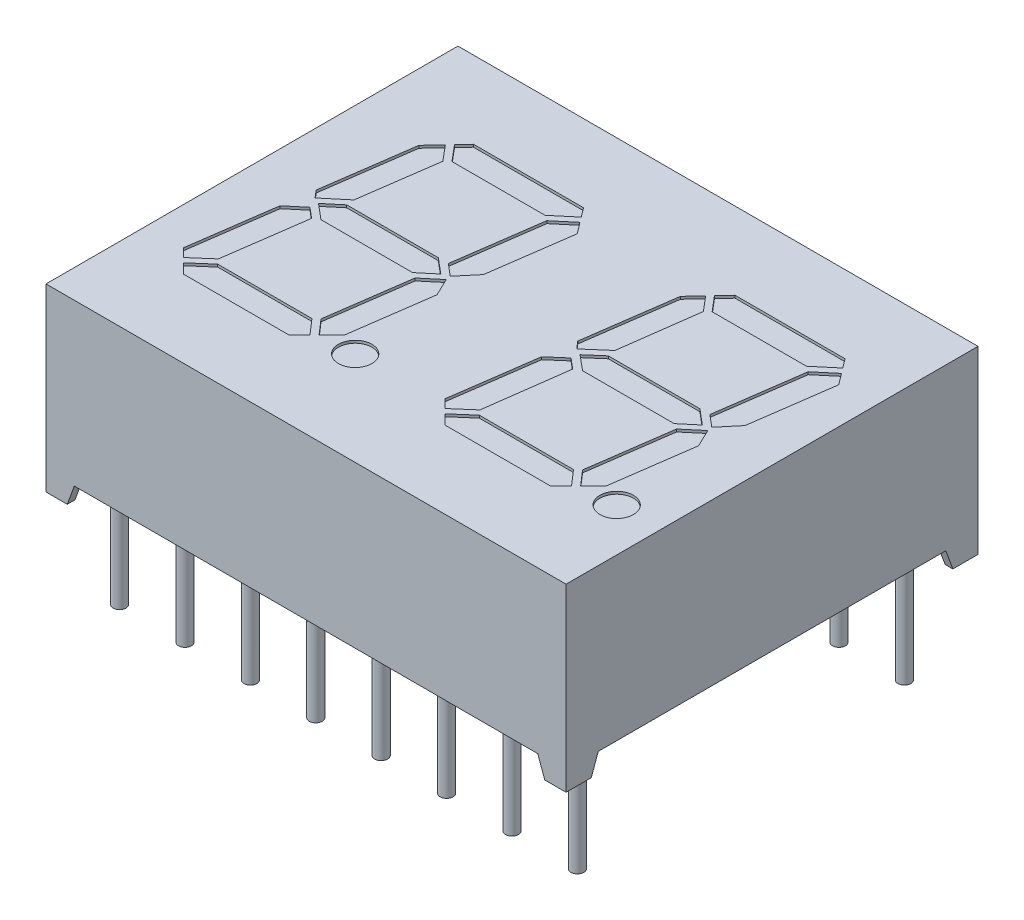
from build123d import *

# Parameters (mm, degrees)
SKETCH1_W          = 20.2
SKETCH1_H          = 16
EXTRUDE2_DEPTH     = 7
CUT_EXTRUDE2_DEPTH = 17
CUT_EXTRUDE3_DEPTH = 21.2
SKETCH6_R          = 0.65
CUT_EXTRUDE4_DEPTH = 0.1
SKETCH7_W          = 0.8
SKETCH7_H          = 0.95
CUT_EXTRUDE6_DEPTH = 0.75
SKETCH7_3_R        = 0.25
EXTRUDE3_DEPTH     = 0.75
SKETCH7_4_R        = 0.25
EXTRUDE4_DEPTH     = 4
SKETCH8_W          = 0.026582278
SKETCH8_H          = 0.025316456
CUT_EXTRUDE7_DEPTH = 0.01


with BuildPart() as part:
    # Sketch1 → Extrude2 (new body)
    with BuildSketch(Plane(origin=(0, 0, 0), x_dir=(1, 0, 0), z_dir=(0, 1, 0))):
        Rectangle(SKETCH1_W, SKETCH1_H)
    extrude(amount=-EXTRUDE2_DEPTH)

    # Sketch2 → Cut-Extrude2 (cut, through all)
    with BuildSketch(Plane.XY.offset(8)):
        Polygon((-9.272977676, -7), (-9, -6.25), (9, -6.25), (9.272977676, -7), align=None)
    extrude(amount=-CUT_EXTRUDE2_DEPTH, mode=Mode.SUBTRACT)

    # Sketch3 → Cut-Extrude3 (cut, through all)
    with BuildSketch(Plane(origin=(10.1, 0, 0), x_dir=(0, 0, -1), z_dir=(1, 0, 0))):
        Polygon((-7.022977676, -7), (-6.75, -6.25), (6.75, -6.25), (7.022977676, -7), align=None)
    extrude(amount=-CUT_EXTRUDE3_DEPTH, mode=Mode.SUBTRACT)

    # Sketch6 → Cut-Extrude4 (cut)
    with BuildSketch(Plane(origin=(0, 0, 0), x_dir=(-1, 0, 0), z_dir=(0, 1, 0))):
        Polygon((7.023157222, -4.434522221), (7.518838203, -3.902969448), (8.010346899, -0.405703354), (7.766925496, -0.115605022), (6.944276877, -0.805889175), (6.51878336, -3.833432859), align=None)
        Polygon((7.552018427, 0.295933465), (8.183414669, 0.825737819), (8.645847239, 4.116116524), (8.319373753, 4.442590009), (7.593183674, 3.811322605), (7.146902379, 0.635866191), align=None)
        Polygon((6.495840663, -5), (6.85137721, -4.618733731), (6.332197964, -4), (2.716150111, -4), (1.952076151, -4.641134178), (2.222500945, -5), align=None)
        Polygon((6.919890443, -0.5), (7.51576724, 0), (6.919890443, 0.5), (3.361644036, 0.5), (2.76576724, 0), (3.361644036, -0.5), align=None)
        Polygon((7.429168917, 4), (8.142165387, 4.619798375), (7.761963762, 5), (3.646933493, 5), (3.247868188, 4.600934695), (3.770252749, 4), align=None)
        Polygon((1.801415921, -4.441201299), (2.500765363, -3.85437744), (2.972247297, -0.499609162), (2.506523905, -0.108820836), (1.91892437, -0.809094694), (1.470232166, -4.001705612), align=None)
        Polygon((3.131453053, 0.633198654), (3.581575354, 3.835985243), (3.070659822, 4.423726329), (2.586273321, 3.939339828), (2.141084503, 0.771656793), (2.473271796, 0.080919003), align=None)
        Polygon((-3.662169854, -4.999993227), (-3.276767134, -4.586267598), (-3.774624408, -3.999993227), (-7.437307761, -3.999993227), (-8.204404285, -4.643663637), (-7.935509571, -4.999993227), align=None)
        Polygon((-3.595238623, -3.839578876), (-3.111665282, -4.409032555), (-2.64024003, -3.902962674), (-2.148731334, -0.40569658), (-2.395060048, -0.121837585), (-3.187587279, -0.809581206), align=None)
        Polygon((-8.688846066, -4.001698839), (-8.35955355, -4.43806542), (-7.656370358, -3.848024664), (-7.186090035, -0.499128511), (-7.652014866, -0.108171158), (-8.240153863, -0.80908792), align=None)
        Polygon((-2.58634694, 0.295802426), (-1.975663564, 0.825744592), (-1.513230994, 4.116123297), (-1.839521605, 4.442413908), (-2.565949288, 3.810939957), (-2.993458449, 0.633342778), align=None)
        Polygon((-2.651691466, 0.009827552), (-3.242886226, 0.499993227), (-6.79742283, 0.499993227), (-7.393310993, 6.773e-06), (-6.797434197, -0.499993227), (-3.239187789, -0.499993227), align=None)
        Polygon((-7.572804912, 3.939346602), (-8.017993729, 0.771663567), (-7.685806437, 0.080925777), (-7.027009117, 0.633696842), (-6.577239772, 3.836533016), (-7.08807549, 4.424076024), align=None)
        Polygon((-2.730302564, 4.000006773), (-2.01709572, 4.619988024), (-2.39711447, 5.000006773), (-6.51214474, 5.000006773), (-6.911470939, 4.600680574), (-6.389218732, 4.000006773), align=None)
        with Locations(Location((1.74076724, 4.35, 0), (0, 0, 270))):  # turned: the seam where the file's is
            Circle(SKETCH6_R)
        with Locations(Location((-8.417243277, 4.350397611, 0), (0, 0, 270))):  # turned: the seam where the file's is
            Circle(SKETCH6_R)
    extrude(amount=-CUT_EXTRUDE4_DEPTH, mode=Mode.SUBTRACT)

    # Sketch7 → Cut-Extrude6 (cut)
    with BuildSketch(Plane.XZ.offset(7)):
        with Locations((-9.4, 7.225)):
            Rectangle(SKETCH7_W, SKETCH7_H)
        with Locations((-9.4, -7.225)):
            Rectangle(SKETCH7_W, SKETCH7_H)
        with Locations((9.4, -7.225)):
            Rectangle(SKETCH7_W, SKETCH7_H)
        with Locations((9.4, 7.225)):
            Rectangle(SKETCH7_W, SKETCH7_H)
    extrude(amount=-CUT_EXTRUDE6_DEPTH, mode=Mode.SUBTRACT)

    # Sketch7_3 → Extrude3 (add)
    with BuildSketch(Plane.XZ.offset(7)):
        with Locations(Location((-3.81, 6.35, 0), (0, 0, 270))):  # turned: the seam where the file's is
            Circle(SKETCH7_3_R)
        with Locations(Location((-1.27, 6.35, 0), (0, 0, 270))):  # turned: the seam where the file's is
            Circle(SKETCH7_3_R)
        with Locations(Location((1.27, 6.35, 0), (0, 0, 270))):  # turned: the seam where the file's is
            Circle(SKETCH7_3_R)
        with Locations(Location((3.81, 6.35, 0), (0, 0, 270))):  # turned: the seam where the file's is
            Circle(SKETCH7_3_R)
        with Locations(Location((6.35, 6.35, 0), (0, 0, 270))):  # turned: the seam where the file's is
            Circle(SKETCH7_3_R)
        with Locations(Location((6.35, -6.35, 0), (0, 0, 270))):  # turned: the seam where the file's is
            Circle(SKETCH7_3_R)
        with Locations(Location((3.81, -6.35, 0), (0, 0, 270))):  # turned: the seam where the file's is
            Circle(SKETCH7_3_R)
        with Locations(Location((1.27, -6.35, 0), (0, 0, 270))):  # turned: the seam where the file's is
            Circle(SKETCH7_3_R)
        with Locations(Location((-1.27, -6.35, 0), (0, 0, 270))):  # turned: the seam where the file's is
            Circle(SKETCH7_3_R)
        with Locations(Location((-3.81, -6.35, 0), (0, 0, 270))):  # turned: the seam where the file's is
            Circle(SKETCH7_3_R)
        with Locations(Location((-6.35, 6.35, 0), (0, 0, 270))):  # turned: the seam where the file's is
            Circle(SKETCH7_3_R)
        with Locations(Location((-8.89, 6.35, 0), (0, 0, 270))):  # turned: the seam where the file's is
            Circle(SKETCH7_3_R)
        with Locations(Location((8.89, 6.35, 0), (0, 0, 270))):  # turned: the seam where the file's is
            Circle(SKETCH7_3_R)
        with Locations(Location((-8.89, -6.35, 0), (0, 0, 270))):  # turned: the seam where the file's is
            Circle(SKETCH7_3_R)
        with Locations(Location((-6.35, -6.35, 0), (0, 0, 270))):  # turned: the seam where the file's is
            Circle(SKETCH7_3_R)
        with Locations(Location((8.89, -6.35, 0), (0, 0, 270))):  # turned: the seam where the file's is
            Circle(SKETCH7_3_R)
    extrude(amount=-EXTRUDE3_DEPTH)

    # Sketch7_4 → Extrude4 (add)
    with BuildSketch(Plane.XZ.offset(7)):
        with Locations(Location((-3.81, 6.35, 0), (0, 0, 270))):  # turned: the seam where the file's is
            Circle(SKETCH7_4_R)
        with Locations(Location((-1.27, 6.35, 0), (0, 0, 270))):  # turned: the seam where the file's is
            Circle(SKETCH7_4_R)
        with Locations(Location((1.27, 6.35, 0), (0, 0, 270))):  # turned: the seam where the file's is
            Circle(SKETCH7_4_R)
        with Locations(Location((3.81, 6.35, 0), (0, 0, 270))):  # turned: the seam where the file's is
            Circle(SKETCH7_4_R)
        with Locations(Location((6.35, 6.35, 0), (0, 0, 270))):  # turned: the seam where the file's is
            Circle(SKETCH7_4_R)
        with Locations(Location((6.35, -6.35, 0), (0, 0, 270))):  # turned: the seam where the file's is
            Circle(SKETCH7_4_R)
        with Locations(Location((3.81, -6.35, 0), (0, 0, 270))):  # turned: the seam where the file's is
            Circle(SKETCH7_4_R)
        with Locations(Location((1.27, -6.35, 0), (0, 0, 270))):  # turned: the seam where the file's is
            Circle(SKETCH7_4_R)
        with Locations(Location((-1.27, -6.35, 0), (0, 0, 270))):  # turned: the seam where the file's is
            Circle(SKETCH7_4_R)
        with Locations(Location((-3.81, -6.35, 0), (0, 0, 270))):  # turned: the seam where the file's is
            Circle(SKETCH7_4_R)
        with Locations(Location((-6.35, 6.35, 0), (0, 0, 270))):  # turned: the seam where the file's is
            Circle(SKETCH7_4_R)
        with Locations(Location((-8.89, 6.35, 0), (0, 0, 270))):  # turned: the seam where the file's is
            Circle(SKETCH7_4_R)
        with Locations(Location((8.89, 6.35, 0), (0, 0, 270))):  # turned: the seam where the file's is
            Circle(SKETCH7_4_R)
        with Locations(Location((-8.89, -6.35, 0), (0, 0, 270))):  # turned: the seam where the file's is
            Circle(SKETCH7_4_R)
        with Locations(Location((-6.35, -6.35, 0), (0, 0, 270))):  # turned: the seam where the file's is
            Circle(SKETCH7_4_R)
        with Locations(Location((8.89, -6.35, 0), (0, 0, 270))):  # turned: the seam where the file's is
            Circle(SKETCH7_4_R)
    extrude(amount=EXTRUDE4_DEPTH)

    # Sketch8 → Cut-Extrude7 (cut)
    with BuildSketch(Plane.XZ.offset(6.25)):
        Polygon((-8.815316456, 0.572151899), (-8.89, 0.595609177), (-8.89, 0.620352057), (-8.839663766, 0.636768196), (-8.89, 0.652294304), (-8.89, 0.678026108), (-8.815316456, 0.701265823), (-8.815316456, 0.676087816), (-8.866799842, 0.663093354), (-8.815316456, 0.646677215), (-8.815316456, 0.625178006), (-8.866799842, 0.608860759), (-8.815316456, 0.596044304), align=None)
        Polygon((-8.815316456, 0.437974684), (-8.89, 0.461431962), (-8.89, 0.486174842), (-8.839663766, 0.502590981), (-8.89, 0.518117089), (-8.89, 0.543848892), (-8.815316456, 0.567088608), (-8.815316456, 0.541910601), (-8.866799842, 0.528916139), (-8.815316456, 0.5125), (-8.815316456, 0.491000791), (-8.866799842, 0.474683544), (-8.815316456, 0.461867089), align=None)
        Polygon((-8.815316456, 0.303797468), (-8.89, 0.327254747), (-8.89, 0.351997627), (-8.839663766, 0.368413766), (-8.89, 0.383939873), (-8.89, 0.409671677), (-8.815316456, 0.432911392), (-8.815316456, 0.407733386), (-8.866799842, 0.394738924), (-8.815316456, 0.378322785), (-8.815316456, 0.356823576), (-8.866799842, 0.340506329), (-8.815316456, 0.327689873), align=None)
        with Locations((-8.876708861, 0.275949367)):
            Rectangle(SKETCH8_W, SKETCH8_H)
        with BuildLine():
            add(Edge.make_bspline(
                [(-8.858829114, 0.159493671), (-8.860051248, 0.159530169), (-8.86245111, 0.15960184), (-8.865958798, 0.160211426), (-8.869283102, 0.161205393), (-8.872447248, 0.162577732), (-8.875416736, 0.164371189), (-8.878219628, 0.16655446), (-8.880824172, 0.169143343), (-8.883260547, 0.172090146), (-8.885442658, 0.175387089), (-8.887348691, 0.178984804), (-8.888943362, 0.18286483), (-8.890282428, 0.187013042), (-8.891270861, 0.191459588), (-8.891994849, 0.196177087), (-8.892468166, 0.201170514), (-8.892510134, 0.204594091), (-8.892531646, 0.206348892)],
                knots=[0, 0, 0, 0, 0.907312236, 1.78165839, 2.635367075, 3.479697475, 4.336364812, 5.205276731, 6.11257575, 7.058770404, 8.040786331, 9.044147278, 10.078219212, 11.153049307, 12.278104542, 13.457648573, 14.696882856, 16, 16, 16, 16], degree=3))
            add(Edge.make_bspline(
                [(-8.892531646, 0.206348892), (-8.892507574, 0.208367148), (-8.892460949, 0.21227633), (-8.89203235, 0.217939855), (-8.891386211, 0.223207892), (-8.890419669, 0.228103607), (-8.889218904, 0.232708206), (-8.887927612, 0.237141474), (-8.886463197, 0.241422786), (-8.885363039, 0.244195876), (-8.884818038, 0.24556962)],
                knots=[0, 0, 0, 0, 1.203215828, 2.33052265, 3.384689099, 4.366106119, 5.303329643, 6.221311756, 7.118865988, 8, 8, 8, 8], degree=3))
            Line((-8.884818038, 0.24556962), (-8.860886076, 0.24556962))
            Line((-8.860886076, 0.24556962), (-8.860886076, 0.242721519))
            add(Edge.make_bspline(
                [(-8.860886076, 0.242721519), (-8.861967531, 0.241356205), (-8.864124092, 0.238633592), (-8.866886697, 0.234200359), (-8.86928886, 0.229552713), (-8.871262862, 0.224707243), (-8.872849186, 0.219810398), (-8.873942713, 0.21493502), (-8.874690062, 0.210169433), (-8.874770569, 0.207010864), (-8.874810127, 0.205458861)],
                knots=[0, 0, 0, 0, 1.030622468, 2.055194264, 3.087043286, 4.125157485, 5.149848264, 6.130935704, 7.081611712, 8, 8, 8, 8], degree=3))
            add(Edge.make_bspline(
                [(-8.874810127, 0.205458861), (-8.874809232, 0.205030082), (-8.874807317, 0.2041121), (-8.874678474, 0.202644063), (-8.874585311, 0.200985464), (-8.874376093, 0.199206598), (-8.87415751, 0.197415781), (-8.87377719, 0.195761121), (-8.873415351, 0.194257482), (-8.873047173, 0.193351), (-8.872871835, 0.192919304)],
                knots=[0, 0, 0, 0, 0.806378557, 1.726393851, 2.771014456, 3.931269413, 5.096090628, 6.161710732, 7.124547685, 8, 8, 8, 8], degree=3))
            add(Edge.make_bspline(
                [(-8.872871835, 0.192919304), (-8.872644012, 0.192439517), (-8.87219629, 0.191496634), (-8.871378683, 0.190201714), (-8.870507381, 0.189019042), (-8.869541962, 0.187957582), (-8.868364053, 0.187107314), (-8.866963197, 0.186479113), (-8.865312897, 0.186136019), (-8.864137886, 0.186096725), (-8.863516614, 0.186075949)],
                knots=[0, 0, 0, 0, 1.024407818, 2.013179384, 2.949802342, 3.859052226, 4.77034807, 5.732977883, 6.801339628, 8, 8, 8, 8], degree=3))
            add(Edge.make_bspline(
                [(-8.863516614, 0.186075949), (-8.862970718, 0.186107391), (-8.861897325, 0.186169215), (-8.860369329, 0.186751006), (-8.858947452, 0.187633905), (-8.857686737, 0.188920927), (-8.856529299, 0.190515003), (-8.855559002, 0.19247074), (-8.854678928, 0.194723719), (-8.854261659, 0.196368178), (-8.854042722, 0.197231013)],
                knots=[0, 0, 0, 0, 0.825212765, 1.622611382, 2.449701629, 3.348069183, 4.336544339, 5.428209675, 6.6506027, 8, 8, 8, 8], degree=3))
            add(Edge.make_bspline(
                [(-8.854042722, 0.197231013), (-8.853594981, 0.19919974), (-8.852677791, 0.203232648), (-8.851530684, 0.209380757), (-8.850264611, 0.215510984), (-8.84905507, 0.219469696), (-8.84846519, 0.221400316)],
                knots=[0, 0, 0, 0, 0.976104583, 1.999535498, 3.024395274, 4, 4, 4, 4], degree=3))
            add(Edge.make_bspline(
                [(-8.84846519, 0.221400316), (-8.848112197, 0.222438832), (-8.847425064, 0.224460401), (-8.846263439, 0.227351945), (-8.844993487, 0.230013057), (-8.843638356, 0.232453168), (-8.842164358, 0.23465249), (-8.840630968, 0.236647679), (-8.838977131, 0.238391205), (-8.837245211, 0.239938889), (-8.835393209, 0.241262203), (-8.833449072, 0.242416954), (-8.831388607, 0.243392589), (-8.829227318, 0.244201473), (-8.82694845, 0.244818545), (-8.824571576, 0.245239801), (-8.822088216, 0.24553819), (-8.820393863, 0.245559001), (-8.819529272, 0.24556962)],
                knots=[0, 0, 0, 0, 1.287286806, 2.505824366, 3.654938963, 4.74627059, 5.778586806, 6.75996495, 7.696030012, 8.595059759, 9.482019644, 10.363222407, 11.245851011, 12.154256429, 13.068444161, 14.012503255, 14.985824751, 16, 16, 16, 16], degree=3))
            add(Edge.make_bspline(
                [(-8.819529272, 0.24556962), (-8.818373127, 0.245532318), (-8.816097855, 0.245458909), (-8.812768811, 0.24485748), (-8.809620074, 0.24383089), (-8.806616611, 0.242444827), (-8.803803525, 0.240616199), (-8.801124978, 0.238431404), (-8.798653386, 0.235807357), (-8.796353053, 0.232830235), (-8.794273654, 0.229542851), (-8.792443098, 0.226003867), (-8.790906446, 0.222234578), (-8.789632552, 0.218249032), (-8.788677881, 0.214030563), (-8.78795895, 0.20959333), (-8.787545768, 0.204919541), (-8.787494518, 0.20172812), (-8.787468354, 0.200098892)],
                knots=[0, 0, 0, 0, 0.894990994, 1.761326291, 2.609044902, 3.454222546, 4.315366365, 5.200560057, 6.125081389, 7.100429509, 8.110379559, 9.133447974, 10.182136699, 11.259192205, 12.370181258, 13.528580438, 14.738335141, 16, 16, 16, 16], degree=3))
            add(Edge.make_bspline(
                [(-8.787468354, 0.200098892), (-8.787490546, 0.198430205), (-8.787534891, 0.19509566), (-8.787912869, 0.190114218), (-8.788468097, 0.185153716), (-8.789309803, 0.180289886), (-8.79028622, 0.175599331), (-8.791382015, 0.171186095), (-8.79261998, 0.167106634), (-8.793574325, 0.16453297), (-8.79403481, 0.163291139)],
                knots=[0, 0, 0, 0, 1.065403572, 2.129000689, 3.188532477, 4.251604565, 5.279552602, 6.247508681, 7.154397237, 8, 8, 8, 8], degree=3))
            Line((-8.79403481, 0.163291139), (-8.816582278, 0.163291139))
            Line((-8.816582278, 0.163291139), (-8.816582278, 0.166119462))
            add(Edge.make_bspline(
                [(-8.816582278, 0.166119462), (-8.815781932, 0.167192367), (-8.814145202, 0.169386485), (-8.81206153, 0.173046122), (-8.810103664, 0.177004358), (-8.808419505, 0.181283188), (-8.806960024, 0.185742216), (-8.805940858, 0.190325174), (-8.805299048, 0.194951338), (-8.805226273, 0.198053049), (-8.805189873, 0.19960443)],
                knots=[0, 0, 0, 0, 0.892283326, 1.824742884, 2.804416662, 3.836872171, 4.8899239, 5.931447339, 6.965372909, 8, 8, 8, 8], degree=3))
            add(Edge.make_bspline(
                [(-8.805189873, 0.19960443), (-8.805211326, 0.200700098), (-8.805254228, 0.202891315), (-8.805644912, 0.206159523), (-8.806275806, 0.209401584), (-8.807095088, 0.211442107), (-8.807503956, 0.212460443)],
                knots=[0, 0, 0, 0, 0.999146175, 1.998183711, 3.000980573, 4, 4, 4, 4], degree=3))
            add(Edge.make_bspline(
                [(-8.807503956, 0.212460443), (-8.807705423, 0.212893946), (-8.808108222, 0.213760664), (-8.808880786, 0.214967308), (-8.809809597, 0.216071977), (-8.810861589, 0.217064055), (-8.812017962, 0.217932452), (-8.813292788, 0.218547803), (-8.814655703, 0.218923676), (-8.815590934, 0.218965835), (-8.816068038, 0.218987342)],
                knots=[0, 0, 0, 0, 1.00524851, 2.009826503, 3.004679593, 4.035271301, 5.048246368, 6.034938417, 6.997532266, 8, 8, 8, 8], degree=3))
            add(Edge.make_bspline(
                [(-8.816068038, 0.218987342), (-8.816706203, 0.218952904), (-8.817925679, 0.218887095), (-8.819641475, 0.218280511), (-8.821119909, 0.217295678), (-8.822114829, 0.216135073), (-8.822812267, 0.215017943), (-8.823322777, 0.213982284), (-8.823806136, 0.212773057), (-8.824303605, 0.211401809), (-8.824794792, 0.209865482), (-8.825270339, 0.208156925), (-8.825719635, 0.206274208), (-8.826005825, 0.204958333), (-8.826155063, 0.204272152)],
                knots=[0, 0, 0, 0, 1.173816843, 2.243057204, 3.312297565, 4.415174738, 5.03266065, 5.73970059, 6.541434878, 7.433956553, 8.430083051, 9.515931566, 10.70464786, 12, 12, 12, 12], degree=3))
            add(Edge.make_bspline(
                [(-8.826155063, 0.204272152), (-8.826531125, 0.202439363), (-8.827270003, 0.198838337), (-8.828373491, 0.193437153), (-8.82964846, 0.18793438), (-8.830797263, 0.184269053), (-8.831396361, 0.182357595)],
                knots=[0, 0, 0, 0, 0.995744513, 1.956417928, 2.934277412, 4, 4, 4, 4], degree=3))
            add(Edge.make_bspline(
                [(-8.831396361, 0.182357595), (-8.831715605, 0.181411041), (-8.832340097, 0.179559428), (-8.83342638, 0.176918797), (-8.834600363, 0.174471738), (-8.835841894, 0.172204706), (-8.83718586, 0.170130736), (-8.838608507, 0.168236053), (-8.840135416, 0.166552235), (-8.841748644, 0.16505467), (-8.843458744, 0.16373551), (-8.845297817, 0.162603212), (-8.847246619, 0.161630984), (-8.849332819, 0.160861379), (-8.851527406, 0.160243358), (-8.853858774, 0.159820261), (-8.85630315, 0.159526278), (-8.857977728, 0.159504661), (-8.858829114, 0.159493671)],
                knots=[0, 0, 0, 0, 1.237467875, 2.420686895, 3.535046182, 4.599015201, 5.620884487, 6.594603852, 7.531477383, 8.433220087, 9.318759595, 10.202828513, 11.105163009, 12.01247538, 12.953896178, 13.926381251, 14.945733412, 16, 16, 16, 16], degree=3))
        make_face()
        with BuildLine():
            Line((-8.89, 0.067088608), (-8.89, 0.091139241))
            Line((-8.89, 0.091139241), (-8.882167722, 0.091139241))
            add(Edge.make_bspline(
                [(-8.882167722, 0.091139241), (-8.88297628, 0.092232549), (-8.884535168, 0.094340433), (-8.886615386, 0.097513458), (-8.888390652, 0.100539548), (-8.889949873, 0.103453039), (-8.891125258, 0.106475242), (-8.891953324, 0.109706756), (-8.892453097, 0.113209581), (-8.892504881, 0.115636475), (-8.892531646, 0.116890823)],
                knots=[0, 0, 0, 0, 1.150872466, 2.218865267, 3.209461834, 4.120482262, 5.012764827, 5.946708227, 6.938749913, 8, 8, 8, 8], degree=3))
            add(Edge.make_bspline(
                [(-8.892531646, 0.116890823), (-8.892508927, 0.117907175), (-8.892464686, 0.119886305), (-8.892119808, 0.122763545), (-8.891582157, 0.125471173), (-8.890774566, 0.127986213), (-8.889808763, 0.130350202), (-8.888528805, 0.132487752), (-8.887098631, 0.134491354), (-8.885391585, 0.136273026), (-8.883493852, 0.137888648), (-8.881361392, 0.139271198), (-8.879028466, 0.140448909), (-8.876476612, 0.141390006), (-8.873718309, 0.142145096), (-8.870739061, 0.142669028), (-8.867551934, 0.142989621), (-8.865356803, 0.14302156), (-8.864228639, 0.143037975)],
                knots=[0, 0, 0, 0, 1.109008058, 2.159558935, 3.158726032, 4.116861086, 5.039058877, 5.938775559, 6.82970133, 7.720510853, 8.624361809, 9.544451588, 10.487360536, 11.471068125, 12.508000841, 13.604731202, 14.768976642, 16, 16, 16, 16], degree=3))
            Line((-8.864228639, 0.143037975), (-8.815316456, 0.143037975))
            Line((-8.815316456, 0.143037975), (-8.815316456, 0.118987342))
            Line((-8.815316456, 0.118987342), (-8.85289557, 0.118987342))
            add(Edge.make_bspline(
                [(-8.85289557, 0.118987342), (-8.853812041, 0.118985706), (-8.855566256, 0.118982576), (-8.858072063, 0.118900237), (-8.860340235, 0.118779336), (-8.862382264, 0.118640631), (-8.864229015, 0.118387615), (-8.865895176, 0.118009906), (-8.867414778, 0.11753908), (-8.868321479, 0.117074761), (-8.868757911, 0.116851266)],
                knots=[0, 0, 0, 0, 1.361401701, 2.605856924, 3.723918663, 4.735739235, 5.645738665, 6.489217889, 7.27279937, 8, 8, 8, 8], degree=3))
            add(Edge.make_bspline(
                [(-8.868757911, 0.116851266), (-8.869156626, 0.116621259), (-8.869940466, 0.116169086), (-8.870946644, 0.115248796), (-8.871790911, 0.114170053), (-8.87244694, 0.112892449), (-8.872945889, 0.111405901), (-8.873286125, 0.109677971), (-8.873501627, 0.107692609), (-8.873529535, 0.106283591), (-8.873544304, 0.105537975)],
                knots=[0, 0, 0, 0, 0.849138082, 1.669332372, 2.503455908, 3.370611167, 4.311442699, 5.394692208, 6.621337967, 8, 8, 8, 8], degree=3))
            add(Edge.make_bspline(
                [(-8.873544304, 0.105537975), (-8.873526947, 0.104996691), (-8.873491259, 0.103883773), (-8.873258814, 0.102172461), (-8.872902139, 0.100375884), (-8.872242283, 0.097861301), (-8.871056104, 0.094694674), (-8.869701697, 0.092335372), (-8.869015032, 0.091139241)],
                knots=[0, 0, 0, 0, 0.638127216, 1.312033637, 2.033062677, 2.79661882, 4.375931797, 6, 6, 6, 6], degree=3))
            Line((-8.869015032, 0.091139241), (-8.815316456, 0.091139241))
            Line((-8.815316456, 0.091139241), (-8.815316456, 0.067088608))
            Line((-8.815316456, 0.067088608), (-8.89, 0.067088608))
        make_face()
        with BuildLine():
            Line((-8.89, -0.030379747), (-8.89, -0.006329114))
            Line((-8.89, -0.006329114), (-8.852420886, -0.006329114))
            add(Edge.make_bspline(
                [(-8.852420886, -0.006329114), (-8.850890843, -0.0063046), (-8.847839818, -0.006255716), (-8.844077407, -0.005973592), (-8.841235083, -0.00559507), (-8.839397202, -0.005225415), (-8.837849063, -0.004793715), (-8.836963303, -0.004381435), (-8.836558544, -0.004193038)],
                knots=[0, 0, 0, 0, 1.709124929, 3.408128882, 4.211124727, 4.91016634, 5.501986363, 6, 6, 6, 6], degree=3))
            add(Edge.make_bspline(
                [(-8.836558544, -0.004193038), (-8.836160491, -0.003948575), (-8.835380051, -0.003469272), (-8.834367038, -0.002531948), (-8.833538197, -0.001438061), (-8.832856647, -0.000167292), (-8.832386066, 0.001323905), (-8.831992836, 0.003040645), (-8.831825927, 0.005027263), (-8.831790767, 0.006434533), (-8.831772152, 0.007179589)],
                knots=[0, 0, 0, 0, 0.86006424, 1.686277094, 2.52783008, 3.38194165, 4.331801563, 5.402842185, 6.624978739, 8, 8, 8, 8], degree=3))
            add(Edge.make_bspline(
                [(-8.831772152, 0.007179589), (-8.831828889, 0.00831141), (-8.831944743, 0.010622505), (-8.83265625, 0.013484698), (-8.833475209, 0.015815302), (-8.83423404, 0.017667827), (-8.835205482, 0.019576457), (-8.835927304, 0.020855869), (-8.836301424, 0.021518987)],
                knots=[0, 0, 0, 0, 1.338371478, 2.732853438, 3.468019217, 4.261884641, 5.099136535, 6, 6, 6, 6], degree=3))
            Line((-8.836301424, 0.021518987), (-8.89, 0.021518987))
            Line((-8.89, 0.021518987), (-8.89, 0.04556962))
            Line((-8.89, 0.04556962), (-8.815316456, 0.04556962))
            Line((-8.815316456, 0.04556962), (-8.815316456, 0.021518987))
            Line((-8.815316456, 0.021518987), (-8.823148734, 0.021518987))
            add(Edge.make_bspline(
                [(-8.823148734, 0.021518987), (-8.822342583, 0.020461581), (-8.82077336, 0.018403276), (-8.81873294, 0.015224038), (-8.816934171, 0.01214014), (-8.815421354, 0.009087131), (-8.814214579, 0.005972176), (-8.81340359, 0.002709417), (-8.812859787, -0.000706989), (-8.812810094, -0.003043704), (-8.81278481, -0.004232595)],
                knots=[0, 0, 0, 0, 1.126119141, 2.192057864, 3.198061997, 4.149848529, 5.076251285, 6.021887753, 6.99356175, 8, 8, 8, 8], degree=3))
            add(Edge.make_bspline(
                [(-8.81278481, -0.004232595), (-8.812810199, -0.005228866), (-8.812859763, -0.007173765), (-8.813169473, -0.010008526), (-8.813720137, -0.012679947), (-8.814517966, -0.015172221), (-8.815503578, -0.017514841), (-8.816735093, -0.019676785), (-8.818193516, -0.021668856), (-8.819854519, -0.023497257), (-8.821744245, -0.025128075), (-8.82386151, -0.026545111), (-8.826204606, -0.027725092), (-8.828764915, -0.028695805), (-8.831530024, -0.029470228), (-8.83452599, -0.029985359), (-8.837730169, -0.030339143), (-8.839946212, -0.030365941), (-8.841087816, -0.030379747)],
                knots=[0, 0, 0, 0, 1.08848837, 2.124922927, 3.110950502, 4.063144162, 4.979605775, 5.882838355, 6.774625441, 7.671951181, 8.57587277, 9.494821853, 10.448322275, 11.435533005, 12.482327682, 13.580118324, 14.753386918, 16, 16, 16, 16], degree=3))
            Line((-8.841087816, -0.030379747), (-8.89, -0.030379747))
        make_face()
        Polygon((-8.89, -0.125316456), (-8.89, -0.053164557), (-8.79, -0.053164557), (-8.79, -0.078481013), (-8.871012658, -0.078481013), (-8.871012658, -0.125316456), align=None)
        Polygon((-8.89, -0.212658228), (-8.89, -0.140506329), (-8.79, -0.140506329), (-8.79, -0.212658228), (-8.808987342, -0.212658228), (-8.808987342, -0.165822785), (-8.826708861, -0.165822785), (-8.826708861, -0.208860759), (-8.845696203, -0.208860759), (-8.845696203, -0.165822785), (-8.871012658, -0.165822785), (-8.871012658, -0.212658228), align=None)
        with BuildLine():
            add(Edge.make_bspline(
                [(-8.840098892, -0.329113924), (-8.841246581, -0.329094609), (-8.843519467, -0.329056357), (-8.846884274, -0.328761165), (-8.850149949, -0.32823514), (-8.853334198, -0.327555959), (-8.856413126, -0.326633453), (-8.859420703, -0.325551739), (-8.862326196, -0.324242093), (-8.865127631, -0.322737241), (-8.867799734, -0.321087768), (-8.870319942, -0.319313019), (-8.87270316, -0.31746724), (-8.874898054, -0.315477927), (-8.876940074, -0.313398746), (-8.878830888, -0.311223217), (-8.880534319, -0.308918153), (-8.881557203, -0.30731099), (-8.882068829, -0.30650712)],
                knots=[0, 0, 0, 0, 1.105570398, 2.18947457, 3.250358341, 4.290584537, 5.323553275, 6.344225964, 7.367641686, 8.3905646, 9.405808457, 10.390761353, 11.358902336, 12.307789878, 13.241960776, 14.165076779, 15.082208636, 16, 16, 16, 16], degree=3))
            add(Edge.make_bspline(
                [(-8.882068829, -0.30650712), (-8.882780968, -0.305267892), (-8.884208881, -0.302783112), (-8.885877472, -0.298799278), (-8.887281588, -0.294673795), (-8.888336012, -0.290323409), (-8.889063056, -0.285676399), (-8.889623862, -0.28067499), (-8.889925622, -0.275267401), (-8.889974642, -0.271532506), (-8.89, -0.269600475)],
                knots=[0, 0, 0, 0, 0.896288622, 1.797150563, 2.705281913, 3.629615989, 4.602417572, 5.655716007, 6.787320449, 8, 8, 8, 8], degree=3))
            Line((-8.89, -0.269600475), (-8.89, -0.234177215))
            Line((-8.89, -0.234177215), (-8.79, -0.234177215))
            Line((-8.79, -0.234177215), (-8.79, -0.270609177))
            add(Edge.make_bspline(
                [(-8.79, -0.270609177), (-8.790016611, -0.272587909), (-8.790048652, -0.276404637), (-8.790466242, -0.281921476), (-8.791063066, -0.287026684), (-8.791987937, -0.291712032), (-8.793103282, -0.296012037), (-8.794462411, -0.299937513), (-8.795961118, -0.303549287), (-8.797234811, -0.305728129), (-8.797852057, -0.306784019)],
                knots=[0, 0, 0, 0, 1.267175336, 2.444223962, 3.542125549, 4.557526608, 5.500936977, 6.385043188, 7.217374394, 8, 8, 8, 8], degree=3))
            add(Edge.make_bspline(
                [(-8.797852057, -0.306784019), (-8.798388598, -0.307634972), (-8.799455511, -0.309327097), (-8.801237363, -0.311728312), (-8.80319344, -0.313957739), (-8.805245259, -0.316086242), (-8.807448146, -0.318066059), (-8.809786853, -0.319909259), (-8.812264947, -0.321613076), (-8.814874416, -0.323171039), (-8.817604468, -0.324591854), (-8.820477527, -0.32578116), (-8.823456057, -0.326830509), (-8.826565019, -0.327636046), (-8.829772856, -0.32833396), (-8.8331142, -0.328768694), (-8.836566688, -0.329055305), (-8.838911578, -0.32909422), (-8.840098892, -0.329113924)],
                knots=[0, 0, 0, 0, 0.964065863, 1.917049184, 2.86229036, 3.805247319, 4.749389377, 5.698846072, 6.657678277, 7.629829384, 8.610569287, 9.604676042, 10.607940105, 11.6349849, 12.681042988, 13.752616828, 14.862056989, 16, 16, 16, 16], degree=3))
        make_face()
        with BuildLine():
            add(Edge.make_bspline(
                [(-8.839940665, -0.302531646), (-8.839135905, -0.302521405), (-8.837557321, -0.302501317), (-8.835241806, -0.30230975), (-8.833012156, -0.302050694), (-8.830877464, -0.30161964), (-8.828817893, -0.301119993), (-8.826860399, -0.300477843), (-8.824980826, -0.299753447), (-8.823203337, -0.298871809), (-8.821494955, -0.297898172), (-8.81990944, -0.296750679), (-8.818396553, -0.295502341), (-8.816968569, -0.294124054), (-8.815662673, -0.292581114), (-8.814432597, -0.290921012), (-8.813304271, -0.289120654), (-8.812644221, -0.287847665), (-8.812310127, -0.287203323)],
                knots=[0, 0, 0, 0, 1.152093354, 2.259898929, 3.325467225, 4.364140538, 5.376172865, 6.358396836, 7.312077728, 8.257828931, 9.196960457, 10.124297759, 11.056236784, 12.004246951, 12.961658638, 13.947279359, 14.960983522, 16, 16, 16, 16], degree=3))
            add(Edge.make_bspline(
                [(-8.812310127, -0.287203323), (-8.812003415, -0.286528425), (-8.81139549, -0.285190731), (-8.810664298, -0.283119908), (-8.810091462, -0.281030524), (-8.809660604, -0.278828925), (-8.809338673, -0.276359165), (-8.809141415, -0.273433583), (-8.808999245, -0.269977674), (-8.808991494, -0.267490959), (-8.808987342, -0.266159019)],
                knots=[0, 0, 0, 0, 0.826967603, 1.639107464, 2.447640171, 3.242670507, 4.14065217, 5.225198036, 6.513753944, 8, 8, 8, 8], degree=3))
            Line((-8.808987342, -0.266159019), (-8.808987342, -0.259493671))
            Line((-8.808987342, -0.259493671), (-8.871012658, -0.259493671))
            Line((-8.871012658, -0.259493671), (-8.871012658, -0.266159019))
            add(Edge.make_bspline(
                [(-8.871012658, -0.266159019), (-8.871007909, -0.266917226), (-8.870998739, -0.268380991), (-8.870955677, -0.270497235), (-8.870908789, -0.272463031), (-8.870792327, -0.274267902), (-8.870719681, -0.275926587), (-8.870541302, -0.277413368), (-8.870399122, -0.278755857), (-8.870131399, -0.280323454), (-8.869715216, -0.28217662), (-8.869037037, -0.28433788), (-8.868186642, -0.286478414), (-8.867501675, -0.287866987), (-8.867155854, -0.288568038)],
                knots=[0, 0, 0, 0, 1.186793418, 2.291178421, 3.313283093, 4.264083014, 5.122158624, 5.910777728, 6.607099052, 7.234812932, 8.398911528, 9.577194775, 10.776795607, 12, 12, 12, 12], degree=3))
            add(Edge.make_bspline(
                [(-8.867155854, -0.288568038), (-8.866814338, -0.289153154), (-8.866140824, -0.29030708), (-8.86500675, -0.291930584), (-8.863799025, -0.293438302), (-8.862510574, -0.294834314), (-8.861122333, -0.296097614), (-8.859655791, -0.297249633), (-8.858107813, -0.298280082), (-8.855914295, -0.299515471), (-8.852883358, -0.300738716), (-8.848915972, -0.301778259), (-8.844556209, -0.30241513), (-8.841518591, -0.302491812), (-8.839940665, -0.302531646)],
                knots=[0, 0, 0, 0, 0.755160452, 1.489275589, 2.205657296, 2.907868421, 3.605098304, 4.296256403, 4.985378686, 5.676536785, 7.100390329, 8.614249252, 10.241231541, 12, 12, 12, 12], degree=3))
        make_face(mode=Mode.SUBTRACT)
        with Locations((-8.876708861, -0.360759494)):
            Rectangle(SKETCH8_W, SKETCH8_H)
        with BuildLine():
            add(Edge.make_bspline(
                [(-8.892531646, -0.435403481), (-8.892509834, -0.433813368), (-8.892467023, -0.430692232), (-8.891990106, -0.42612089), (-8.89127241, -0.421755717), (-8.890251504, -0.417609409), (-8.888904008, -0.413695618), (-8.887251072, -0.41003198), (-8.885265888, -0.406625123), (-8.883686679, -0.404566476), (-8.882899525, -0.403540348)],
                knots=[0, 0, 0, 0, 1.123670284, 2.205584497, 3.245308791, 4.249063313, 5.220352711, 6.167273909, 7.086481357, 8, 8, 8, 8], degree=3))
            add(Edge.make_bspline(
                [(-8.882899525, -0.403540348), (-8.882044751, -0.402588601), (-8.880338508, -0.400688786), (-8.877367081, -0.398222853), (-8.874084037, -0.396099767), (-8.870481815, -0.394314215), (-8.866565086, -0.392883291), (-8.862320424, -0.391860157), (-8.857759643, -0.391240912), (-8.85461171, -0.391173746), (-8.852994462, -0.391139241)],
                knots=[0, 0, 0, 0, 0.916457077, 1.82937027, 2.759194969, 3.714948755, 4.706655623, 5.743329475, 6.840637961, 8, 8, 8, 8], degree=3))
            add(Edge.make_bspline(
                [(-8.852994462, -0.391139241), (-8.851291235, -0.391178001), (-8.847990155, -0.391253124), (-8.843217967, -0.391916883), (-8.838800287, -0.392986496), (-8.834748378, -0.394524054), (-8.831055187, -0.396454496), (-8.827683352, -0.398718989), (-8.824640428, -0.401339514), (-8.822894988, -0.403346653), (-8.822021361, -0.404351266)],
                knots=[0, 0, 0, 0, 1.171797512, 2.271099083, 3.308930235, 4.294129479, 5.24602549, 6.17106565, 7.084581485, 8, 8, 8, 8], degree=3))
            add(Edge.make_bspline(
                [(-8.822021361, -0.404351266), (-8.821252774, -0.405377136), (-8.819706318, -0.407441268), (-8.817805619, -0.410844773), (-8.816210833, -0.414467988), (-8.814963188, -0.418297559), (-8.814009283, -0.422270367), (-8.813285439, -0.426330027), (-8.812864881, -0.43047628), (-8.812811629, -0.43326648), (-8.81278481, -0.434671677)],
                knots=[0, 0, 0, 0, 0.952130878, 1.915761808, 2.890227217, 3.891541892, 4.905612075, 5.925811839, 6.955400088, 8, 8, 8, 8], degree=3))
            add(Edge.make_bspline(
                [(-8.81278481, -0.434671677), (-8.812801812, -0.435918396), (-8.812835245, -0.438369867), (-8.813157354, -0.441970914), (-8.813690473, -0.445425455), (-8.814429076, -0.448730387), (-8.815320679, -0.451904334), (-8.81635982, -0.454954511), (-8.817493088, -0.457914321), (-8.818377623, -0.45981489), (-8.818817247, -0.460759494)],
                knots=[0, 0, 0, 0, 1.107648782, 2.178012834, 3.209595929, 4.211695017, 5.185427128, 6.137685403, 7.07440854, 8, 8, 8, 8], degree=3))
            Line((-8.818817247, -0.460759494), (-8.839367089, -0.460759494))
            Line((-8.839367089, -0.460759494), (-8.839367089, -0.45741693))
            add(Edge.make_bspline(
                [(-8.839367089, -0.45741693), (-8.838949869, -0.456917386), (-8.838048154, -0.45583775), (-8.836627402, -0.454051335), (-8.835097809, -0.451902393), (-8.834205863, -0.450248857), (-8.833730222, -0.449367089)],
                knots=[0, 0, 0, 0, 0.792826818, 1.713491785, 2.780691913, 4, 4, 4, 4], degree=3))
            add(Edge.make_bspline(
                [(-8.833730222, -0.449367089), (-8.833288264, -0.448439154), (-8.832382404, -0.446537209), (-8.83154957, -0.443981204), (-8.830981844, -0.441789202), (-8.830725422, -0.439971666), (-8.830535861, -0.438038046), (-8.830516354, -0.436702803), (-8.830506329, -0.436016614)],
                knots=[0, 0, 0, 0, 1.332524827, 2.731214173, 3.480270227, 4.267952375, 5.109889624, 6, 6, 6, 6], degree=3))
            add(Edge.make_bspline(
                [(-8.830506329, -0.436016614), (-8.830525879, -0.435251058), (-8.830563765, -0.433767448), (-8.830840821, -0.431605939), (-8.831319079, -0.429587528), (-8.831959179, -0.427684306), (-8.832846792, -0.425946243), (-8.833880429, -0.424319403), (-8.835106231, -0.422827143), (-8.836547173, -0.421507882), (-8.838127102, -0.420315156), (-8.839861217, -0.419295954), (-8.841707816, -0.418383498), (-8.843712265, -0.41768856), (-8.845841041, -0.417128822), (-8.848104161, -0.416739892), (-8.850503671, -0.416497934), (-8.852149979, -0.416470016), (-8.852994462, -0.416455696)],
                knots=[0, 0, 0, 0, 1.087302107, 2.107140881, 3.088415001, 4.030197574, 4.951552271, 5.852940509, 6.764198256, 7.685219758, 8.621679636, 9.570836121, 10.538340132, 11.542450476, 12.578202196, 13.66207107, 14.800746211, 16, 16, 16, 16], degree=3))
            add(Edge.make_bspline(
                [(-8.852994462, -0.416455696), (-8.853858618, -0.416470471), (-8.855537631, -0.416499177), (-8.857979242, -0.416732691), (-8.860260673, -0.417148582), (-8.862385993, -0.41771983), (-8.864352011, -0.418444178), (-8.866149408, -0.419349295), (-8.867806215, -0.420385652), (-8.869268827, -0.42163021), (-8.870585149, -0.422994093), (-8.871721283, -0.424508985), (-8.872669428, -0.426168224), (-8.873473891, -0.427950405), (-8.874052289, -0.429883445), (-8.874488981, -0.431939982), (-8.874777538, -0.434129537), (-8.874799101, -0.435639891), (-8.874810127, -0.436412184)],
                knots=[0, 0, 0, 0, 1.230336593, 2.390482092, 3.487897344, 4.52859895, 5.520747884, 6.465347575, 7.38981449, 8.296085817, 9.192433006, 10.084246191, 10.984321635, 11.908883871, 12.862027947, 13.850751296, 14.901019963, 16, 16, 16, 16], degree=3))
            add(Edge.make_bspline(
                [(-8.874810127, -0.436412184), (-8.874801999, -0.437138038), (-8.874786155, -0.438553063), (-8.874568078, -0.44061781), (-8.874292195, -0.442578718), (-8.873852787, -0.444414258), (-8.873310412, -0.446109524), (-8.872743906, -0.447669947), (-8.872139122, -0.449082395), (-8.871671567, -0.449943749), (-8.871447785, -0.450356013)],
                knots=[0, 0, 0, 0, 1.200823684, 2.340960236, 3.433630075, 4.476504061, 5.46014544, 6.378484521, 7.223905657, 8, 8, 8, 8], degree=3))
            add(Edge.make_bspline(
                [(-8.871447785, -0.450356013), (-8.87101789, -0.451056218), (-8.870186248, -0.452410785), (-8.868784682, -0.454249513), (-8.867370422, -0.455894382), (-8.866414205, -0.456918894), (-8.865949367, -0.45741693)],
                knots=[0, 0, 0, 0, 1.098601379, 2.125273733, 3.088655601, 4, 4, 4, 4], degree=3))
            Line((-8.865949367, -0.45741693), (-8.865949367, -0.460759494))
            Line((-8.865949367, -0.460759494), (-8.886657437, -0.460759494))
            add(Edge.make_bspline(
                [(-8.886657437, -0.460759494), (-8.887094931, -0.459814104), (-8.887970024, -0.457923097), (-8.889123896, -0.455008518), (-8.890092057, -0.452020545), (-8.890995137, -0.448972172), (-8.891683499, -0.445800089), (-8.892176622, -0.442477058), (-8.892477534, -0.43899556), (-8.892513362, -0.436617171), (-8.892531646, -0.435403481)],
                knots=[0, 0, 0, 0, 0.952012952, 1.904254716, 2.862729541, 3.822037426, 4.808956931, 5.82647221, 6.890850784, 8, 8, 8, 8], degree=3))
        make_face()
        with BuildLine():
            add(Edge.make_bspline(
                [(-8.852697785, -0.553164557), (-8.854202691, -0.553139862), (-8.857136157, -0.553091723), (-8.861407948, -0.552552407), (-8.865443946, -0.551739627), (-8.869231154, -0.550567096), (-8.872788429, -0.549086703), (-8.876078221, -0.547235764), (-8.879131451, -0.545064759), (-8.881921336, -0.542573722), (-8.884419846, -0.53977252), (-8.886615099, -0.536698338), (-8.888428541, -0.533324511), (-8.889940631, -0.5297102), (-8.891109866, -0.525825548), (-8.891922584, -0.521671329), (-8.892458054, -0.517254195), (-8.892506706, -0.514215776), (-8.892531646, -0.512658228)],
                knots=[0, 0, 0, 0, 1.120167703, 2.183507516, 3.201345984, 4.182878364, 5.131270247, 6.065524964, 6.98789854, 7.91635504, 8.84481154, 9.778033504, 10.722808862, 11.691211189, 12.691525459, 13.738229926, 14.840575679, 16, 16, 16, 16], degree=3))
            add(Edge.make_bspline(
                [(-8.892531646, -0.512658228), (-8.892506624, -0.511100707), (-8.892457811, -0.508062341), (-8.89192348, -0.503644832), (-8.891105529, -0.499485737), (-8.889949428, -0.49559643), (-8.888422879, -0.491987684), (-8.886615831, -0.488617817), (-8.884419638, -0.485544052), (-8.881921446, -0.482742566), (-8.879131219, -0.480252248), (-8.876079037, -0.478078657), (-8.872783083, -0.476236243), (-8.869240037, -0.474718389), (-8.865439199, -0.473585065), (-8.861408758, -0.472761602), (-8.857135938, -0.472225394), (-8.854202617, -0.472176819), (-8.852697785, -0.472151899)],
                knots=[0, 0, 0, 0, 1.15937715, 2.261678054, 3.308339936, 4.313313916, 5.277148057, 6.221884977, 7.155068972, 8.083487698, 9.011906424, 9.934242473, 10.868459181, 11.818729666, 12.798784262, 13.81658132, 14.879877871, 16, 16, 16, 16], degree=3))
            add(Edge.make_bspline(
                [(-8.852697785, -0.472151899), (-8.851186361, -0.472177022), (-8.848233351, -0.472226107), (-8.843934478, -0.472761477), (-8.839873828, -0.473579494), (-8.836065514, -0.474739526), (-8.832513914, -0.476255799), (-8.82921181, -0.478096824), (-8.826165235, -0.480293292), (-8.823375483, -0.48280279), (-8.820879102, -0.485614584), (-8.818706197, -0.488708516), (-8.816869539, -0.492060435), (-8.815347706, -0.495667634), (-8.814213141, -0.49955419), (-8.813395562, -0.503691132), (-8.81285749, -0.508088526), (-8.812809478, -0.511107264), (-8.81278481, -0.512658228)],
                knots=[0, 0, 0, 0, 1.124034801, 2.196132384, 3.217834281, 4.203147447, 5.152578239, 6.085969439, 7.010345409, 7.941219594, 8.872481455, 9.802010446, 10.748267785, 11.711250247, 12.709230373, 13.754967386, 14.846549946, 16, 16, 16, 16], degree=3))
            add(Edge.make_bspline(
                [(-8.81278481, -0.512658228), (-8.812809532, -0.514228966), (-8.812857665, -0.51728713), (-8.813393868, -0.521730542), (-8.814206873, -0.525904381), (-8.815373269, -0.529803006), (-8.816884682, -0.533428756), (-8.81871934, -0.536788831), (-8.820921398, -0.539860139), (-8.823428554, -0.542647393), (-8.826233956, -0.545127634), (-8.829283579, -0.54729655), (-8.832603295, -0.549103768), (-8.836158163, -0.550585538), (-8.839951933, -0.551757711), (-8.843986038, -0.552578696), (-8.848261035, -0.553084687), (-8.851193165, -0.553137471), (-8.852697785, -0.553164557)],
                knots=[0, 0, 0, 0, 1.167358552, 2.272800965, 3.322628764, 4.326027541, 5.29287265, 6.238482395, 7.166210353, 8.096447471, 9.020151799, 9.945039072, 10.873038967, 11.824425184, 12.804379233, 13.820580988, 14.881633558, 16, 16, 16, 16], degree=3))
        make_face()
        with BuildLine():
            add(Edge.make_bspline(
                [(-8.871190665, -0.523457278), (-8.870690658, -0.523812456), (-8.869673086, -0.524535285), (-8.867972663, -0.525405537), (-8.866150868, -0.526193542), (-8.864121587, -0.526811737), (-8.861819141, -0.527291059), (-8.859165549, -0.52760245), (-8.856130036, -0.527832094), (-8.853977323, -0.527842556), (-8.852836234, -0.527848101)],
                knots=[0, 0, 0, 0, 0.764956307, 1.556776596, 2.379454426, 3.241401993, 4.200532455, 5.312591107, 6.575484591, 8, 8, 8, 8], degree=3))
            add(Edge.make_bspline(
                [(-8.852836234, -0.527848101), (-8.851761353, -0.527830412), (-8.849701996, -0.527796522), (-8.846742233, -0.527610152), (-8.844058807, -0.527261478), (-8.841641411, -0.5267636), (-8.839470723, -0.526153829), (-8.83752836, -0.525427894), (-8.835809758, -0.524589376), (-8.834804527, -0.523903909), (-8.834323576, -0.523575949)],
                knots=[0, 0, 0, 0, 1.337076348, 2.561692668, 3.686680134, 4.69989255, 5.629188848, 6.488203485, 7.276684665, 8, 8, 8, 8], degree=3))
            add(Edge.make_bspline(
                [(-8.834323576, -0.523575949), (-8.833884293, -0.523238652), (-8.833022537, -0.522576962), (-8.831940352, -0.521400911), (-8.831042058, -0.520136352), (-8.830382017, -0.51875605), (-8.829862759, -0.517310883), (-8.829515923, -0.515802557), (-8.829287802, -0.514247405), (-8.829256424, -0.513193069), (-8.829240506, -0.512658228)],
                knots=[0, 0, 0, 0, 1.058684453, 2.076859345, 3.046867319, 4.017860406, 4.996047344, 5.981941452, 6.976284511, 8, 8, 8, 8], degree=3))
            add(Edge.make_bspline(
                [(-8.829240506, -0.512658228), (-8.829251453, -0.512130296), (-8.829272863, -0.511097679), (-8.829452545, -0.509595013), (-8.829747135, -0.508184065), (-8.830165068, -0.506844191), (-8.830760551, -0.505552217), (-8.831616975, -0.504317872), (-8.832692306, -0.503101936), (-8.833542825, -0.502363688), (-8.833987342, -0.501977848)],
                knots=[0, 0, 0, 0, 1.041978199, 2.038073998, 2.982578265, 3.884042198, 4.804014415, 5.778706634, 6.839057036, 8, 8, 8, 8], degree=3))
            add(Edge.make_bspline(
                [(-8.833987342, -0.501977848), (-8.834461968, -0.501644363), (-8.835460568, -0.500942719), (-8.837165089, -0.500059744), (-8.839127009, -0.49932839), (-8.84131075, -0.49863615), (-8.843781898, -0.498117886), (-8.846535176, -0.497717147), (-8.849589603, -0.497516433), (-8.85172182, -0.497484858), (-8.852836234, -0.497468354)],
                knots=[0, 0, 0, 0, 0.706185926, 1.485796665, 2.33004681, 3.254820698, 4.274138656, 5.402098861, 6.642194297, 8, 8, 8, 8], degree=3))
            add(Edge.make_bspline(
                [(-8.852836234, -0.497468354), (-8.853838698, -0.497477501), (-8.85577981, -0.497495212), (-8.858586195, -0.497694126), (-8.861190128, -0.498022802), (-8.86358016, -0.498499446), (-8.865765057, -0.49907369), (-8.867716716, -0.499821164), (-8.869471774, -0.500644638), (-8.870499515, -0.501344976), (-8.87099288, -0.501681171)],
                knots=[0, 0, 0, 0, 1.270915159, 2.460926195, 3.565223763, 4.596447547, 5.549594966, 6.425286377, 7.244063354, 8, 8, 8, 8], degree=3))
            add(Edge.make_bspline(
                [(-8.87099288, -0.501681171), (-8.871409366, -0.502021731), (-8.872230494, -0.502693168), (-8.873314509, -0.503842086), (-8.87417586, -0.505125798), (-8.874906348, -0.506477001), (-8.875435594, -0.507938804), (-8.875812201, -0.509490696), (-8.876027955, -0.511142431), (-8.876059682, -0.512275225), (-8.876075949, -0.512856013)],
                knots=[0, 0, 0, 0, 1.011121112, 1.993489184, 2.956264801, 3.910060304, 4.874908638, 5.87009835, 6.907993364, 8, 8, 8, 8], degree=3))
            add(Edge.make_bspline(
                [(-8.876075949, -0.512856013), (-8.876022367, -0.513856962), (-8.875915445, -0.515854325), (-8.875203793, -0.518269474), (-8.874354513, -0.520076797), (-8.873475258, -0.521316068), (-8.872435719, -0.522472259), (-8.871609742, -0.523125727), (-8.871190665, -0.523457278)],
                knots=[0, 0, 0, 0, 1.48399549, 2.96126462, 3.700919455, 4.439278468, 5.208134679, 6, 6, 6, 6], degree=3))
        make_face(mode=Mode.SUBTRACT)
        with BuildLine():
            Line((-8.836301424, -0.644303797), (-8.89, -0.644303797))
            Line((-8.89, -0.644303797), (-8.89, -0.620253165))
            Line((-8.89, -0.620253165), (-8.852143987, -0.620253165))
            add(Edge.make_bspline(
                [(-8.852143987, -0.620253165), (-8.851253953, -0.620247698), (-8.849546322, -0.62023721), (-8.847086708, -0.620204186), (-8.844838103, -0.620123915), (-8.842791904, -0.620016376), (-8.840932439, -0.619829431), (-8.839257604, -0.619518092), (-8.837752078, -0.619096595), (-8.83685113, -0.618688245), (-8.836420095, -0.61849288)],
                knots=[0, 0, 0, 0, 1.339742217, 2.570446543, 3.702449567, 4.726327994, 5.654556215, 6.512888379, 7.288529137, 8, 8, 8, 8], degree=3))
            add(Edge.make_bspline(
                [(-8.836420095, -0.61849288), (-8.836034728, -0.618282954), (-8.835270835, -0.61786683), (-8.834302974, -0.616998785), (-8.833492329, -0.615990476), (-8.832850874, -0.614810314), (-8.832352712, -0.613431631), (-8.832003366, -0.611816509), (-8.831822964, -0.609952652), (-8.831789727, -0.608630364), (-8.831772152, -0.607931171)],
                knots=[0, 0, 0, 0, 0.859345536, 1.703436662, 2.532498256, 3.390183975, 4.328249457, 5.402602062, 6.626559876, 8, 8, 8, 8], degree=3))
            add(Edge.make_bspline(
                [(-8.831772152, -0.607931171), (-8.831795714, -0.607343877), (-8.831843051, -0.60616399), (-8.83208459, -0.604405516), (-8.832586536, -0.602686303), (-8.833423174, -0.600467627), (-8.834639641, -0.597858323), (-8.83576153, -0.595885907), (-8.836301424, -0.594936709)],
                knots=[0, 0, 0, 0, 0.759443456, 1.525737455, 2.286422378, 3.068189154, 4.58910569, 6, 6, 6, 6], degree=3))
            Line((-8.836301424, -0.594936709), (-8.89, -0.594936709))
            Line((-8.89, -0.594936709), (-8.89, -0.570886076))
            Line((-8.89, -0.570886076), (-8.815316456, -0.570886076))
            Line((-8.815316456, -0.570886076), (-8.815316456, -0.594936709))
            Line((-8.815316456, -0.594936709), (-8.823148734, -0.594936709))
            add(Edge.make_bspline(
                [(-8.823148734, -0.594936709), (-8.822367252, -0.595957746), (-8.820849932, -0.597940187), (-8.818803995, -0.60095416), (-8.81704056, -0.603909643), (-8.815510003, -0.606810759), (-8.814254621, -0.609757207), (-8.813417856, -0.612851706), (-8.812885536, -0.616094453), (-8.812818794, -0.618312736), (-8.81278481, -0.619442247)],
                knots=[0, 0, 0, 0, 1.136140478, 2.205924536, 3.217129804, 4.176128364, 5.103417168, 6.04061054, 7.002313223, 8, 8, 8, 8], degree=3))
            add(Edge.make_bspline(
                [(-8.81278481, -0.619442247), (-8.812816556, -0.62064549), (-8.8128786, -0.622997145), (-8.813547861, -0.626409066), (-8.814552486, -0.629624954), (-8.816042919, -0.632580961), (-8.81787572, -0.635303105), (-8.820153427, -0.637694085), (-8.822799233, -0.639808625), (-8.824810869, -0.640898753), (-8.825838608, -0.641455696)],
                knots=[0, 0, 0, 0, 1.06605855, 2.083537511, 3.073064962, 4.046068917, 5.009676085, 5.97370914, 6.964773701, 8, 8, 8, 8], degree=3))
            add(Edge.make_bspline(
                [(-8.825838608, -0.641455696), (-8.824861648, -0.642637783), (-8.822957743, -0.644941441), (-8.820415047, -0.648495035), (-8.818160747, -0.651974192), (-8.816251034, -0.655414444), (-8.814706146, -0.658810095), (-8.813600545, -0.662189222), (-8.812917099, -0.665538003), (-8.812828397, -0.667771262), (-8.81278481, -0.668868671)],
                knots=[0, 0, 0, 0, 1.188124574, 2.315425566, 3.384037189, 4.39937427, 5.362203716, 6.270239573, 7.150007311, 8, 8, 8, 8], degree=3))
            add(Edge.make_bspline(
                [(-8.81278481, -0.668868671), (-8.812808185, -0.66985193), (-8.812853665, -0.671765088), (-8.813188962, -0.67454753), (-8.8137597, -0.677144118), (-8.814553952, -0.679566684), (-8.815577368, -0.681809925), (-8.816851198, -0.68386078), (-8.818357379, -0.685715362), (-8.820057184, -0.687408252), (-8.821991531, -0.688889581), (-8.824119192, -0.690193193), (-8.826470211, -0.69124157), (-8.828998325, -0.692146787), (-8.831735603, -0.692828576), (-8.834678201, -0.693319319), (-8.837818223, -0.693617336), (-8.839979558, -0.693652735), (-8.841087816, -0.693670886)],
                knots=[0, 0, 0, 0, 1.099321551, 2.138985818, 3.128101353, 4.067593225, 4.984602876, 5.878565082, 6.75932895, 7.650734189, 8.554641537, 9.477588118, 10.434248276, 11.427530835, 12.477080043, 13.583595796, 14.760951851, 16, 16, 16, 16], degree=3))
            Line((-8.841087816, -0.693670886), (-8.89, -0.693670886))
            Line((-8.89, -0.693670886), (-8.89, -0.669620253))
            Line((-8.89, -0.669620253), (-8.852143987, -0.669620253))
            add(Edge.make_bspline(
                [(-8.852143987, -0.669620253), (-8.851247371, -0.669614543), (-8.849526576, -0.669603583), (-8.847060222, -0.669573902), (-8.844812405, -0.669484266), (-8.842772514, -0.669403721), (-8.84092038, -0.6692351), (-8.839248731, -0.668948066), (-8.837756742, -0.668517939), (-8.836851818, -0.668126047), (-8.836420095, -0.667939082)],
                knots=[0, 0, 0, 0, 1.350843832, 2.592553583, 3.715618503, 4.739861077, 5.667890227, 6.515410335, 7.291728161, 8, 8, 8, 8], degree=3))
            add(Edge.make_bspline(
                [(-8.836420095, -0.667939082), (-8.836035088, -0.667735705), (-8.83527283, -0.667333048), (-8.834297859, -0.666483931), (-8.833487251, -0.66547211), (-8.832851921, -0.66427512), (-8.832349458, -0.662871659), (-8.832008014, -0.661235308), (-8.831820551, -0.659346374), (-8.831788988, -0.658010726), (-8.831772152, -0.657298259)],
                knots=[0, 0, 0, 0, 0.846473755, 1.675897046, 2.498822796, 3.361436039, 4.304631926, 5.39613934, 6.611038701, 8, 8, 8, 8], degree=3))
            add(Edge.make_bspline(
                [(-8.831772152, -0.657298259), (-8.831819388, -0.656297285), (-8.831914406, -0.654283768), (-8.832631155, -0.651800391), (-8.833445787, -0.649778602), (-8.83422506, -0.648078656), (-8.835194386, -0.64623747), (-8.835921526, -0.644967369), (-8.836301424, -0.644303797)],
                knots=[0, 0, 0, 0, 1.291138276, 2.597198332, 3.312242316, 4.108946311, 5.012008063, 6, 6, 6, 6], degree=3))
        make_face()
    extrude(amount=-CUT_EXTRUDE7_DEPTH, mode=Mode.SUBTRACT)


solid = part.part
